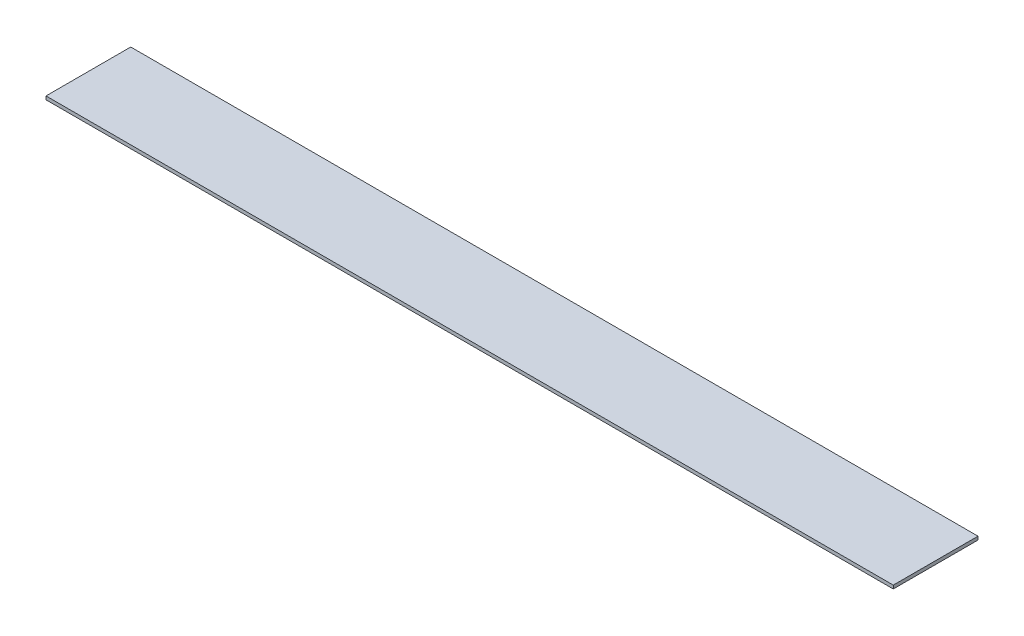
from build123d import *

# Parameters (mm, degrees)
SKETCH1_W           = 250
SKETCH1_H           = 25
BOSS_EXTRUDE1_DEPTH = 1


with BuildPart() as part:
    # Sketch1 → Boss-Extrude1 (new body)
    with BuildSketch(Plane(origin=(0, 0, 0), x_dir=(1, 0, 0), z_dir=(0, 1, 0))):
        with Locations((125, 12.5)):
            Rectangle(SKETCH1_W, SKETCH1_H)
    extrude(amount=BOSS_EXTRUDE1_DEPTH)


solid = part.part
